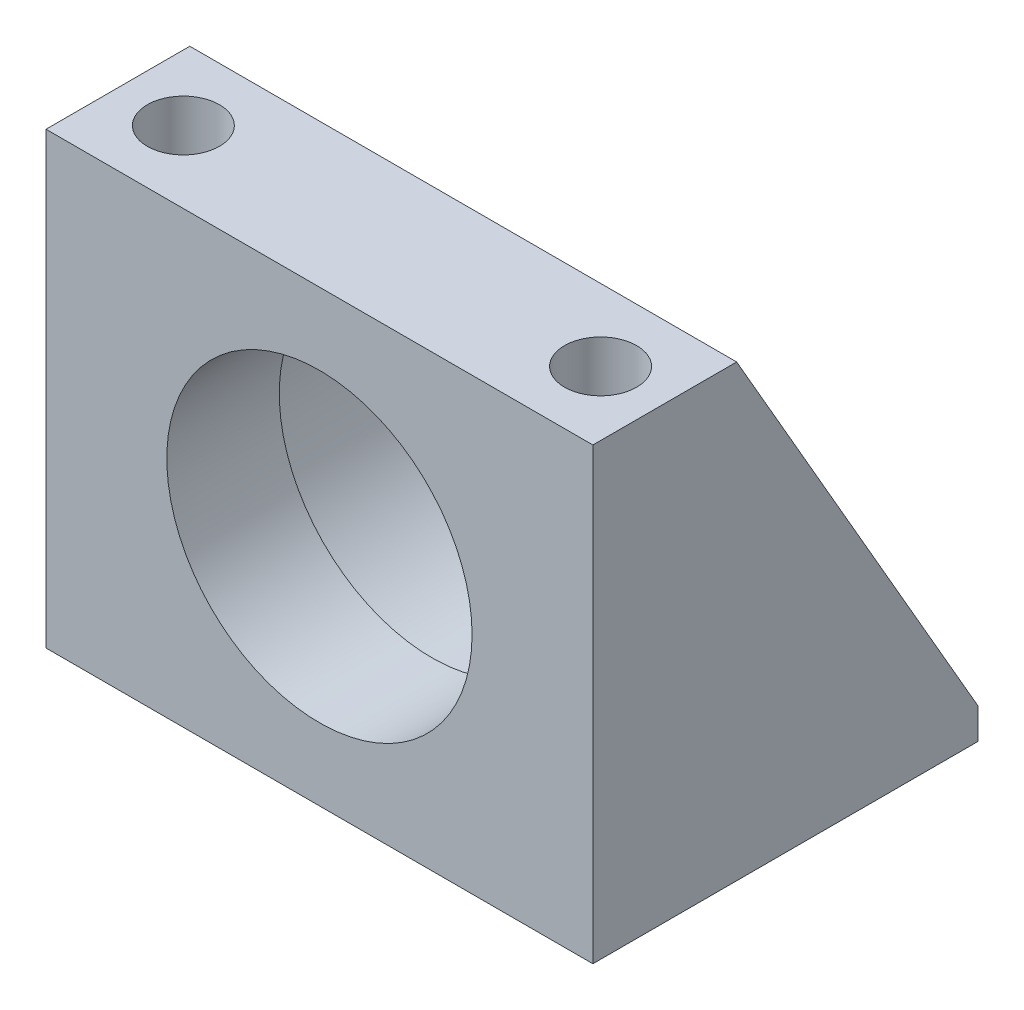
from build123d import *

# Parameters (mm, degrees)
SKETCH1_W          = 54.102
SKETCH1_H          = 44.45
SKETCH1_R          = 15.1003
EXTRUDE1_DEPTH     = 38.1
CUT_EXTRUDE1_DEPTH = 55.102
SKETCH3_R          = 17.526
CUT_EXTRUDE2_DEPTH = 26.9748
FILLET1_R          = 1.524
HOLE1_D            = 7.1374
HOLE1_DEPTH        = 44.45


with BuildPart() as part:
    # Sketch1 → Extrude1 (new body)
    with BuildSketch(Plane.XY):
        with Locations((0, 22.225)):
            Rectangle(SKETCH1_W, SKETCH1_H)
        with Locations((0, 22.225)):
            Circle(SKETCH1_R, mode=Mode.SUBTRACT)
    extrude(amount=-EXTRUDE1_DEPTH)

    # Sketch2 → Cut-Extrude1 (cut, through all)
    with BuildSketch(Plane(origin=(27.051, 0, 0), x_dir=(0, 0, -1), z_dir=(1, 0, 0))):
        Polygon((14.224, 44.45), (38.1, 3.048), (38.1, 44.45), align=None)
    extrude(amount=-CUT_EXTRUDE1_DEPTH, mode=Mode.SUBTRACT)

    # Sketch3 → Cut-Extrude2 (cut)
    with BuildSketch(Plane(origin=(0, 0, -38.1), x_dir=(-1, 0, 0), z_dir=(0, 0, -1))):
        with Locations(Location((0, 22.225, 0), (0, 0, 270))):  # turned: the seam where the file's is
            Circle(SKETCH3_R)
    extrude(amount=-CUT_EXTRUDE2_DEPTH, mode=Mode.SUBTRACT)

    # Fillet1
    fillet1_edges = [part.edges().sort_by_distance(p)[0] for p in [
        (0, 39.751, -11.1252),
    ]]
    fillet(fillet1_edges, radius=FILLET1_R)

    # Hole1
    with Locations(Plane(origin=(0, 44.45, 0), x_dir=(-1, 0, 0), z_dir=(0, 1, 0))):
        with Locations((20.574, -7.112), (-20.701, -7.112)):
            Hole(HOLE1_D / 2, depth=HOLE1_DEPTH)


solid = part.part
